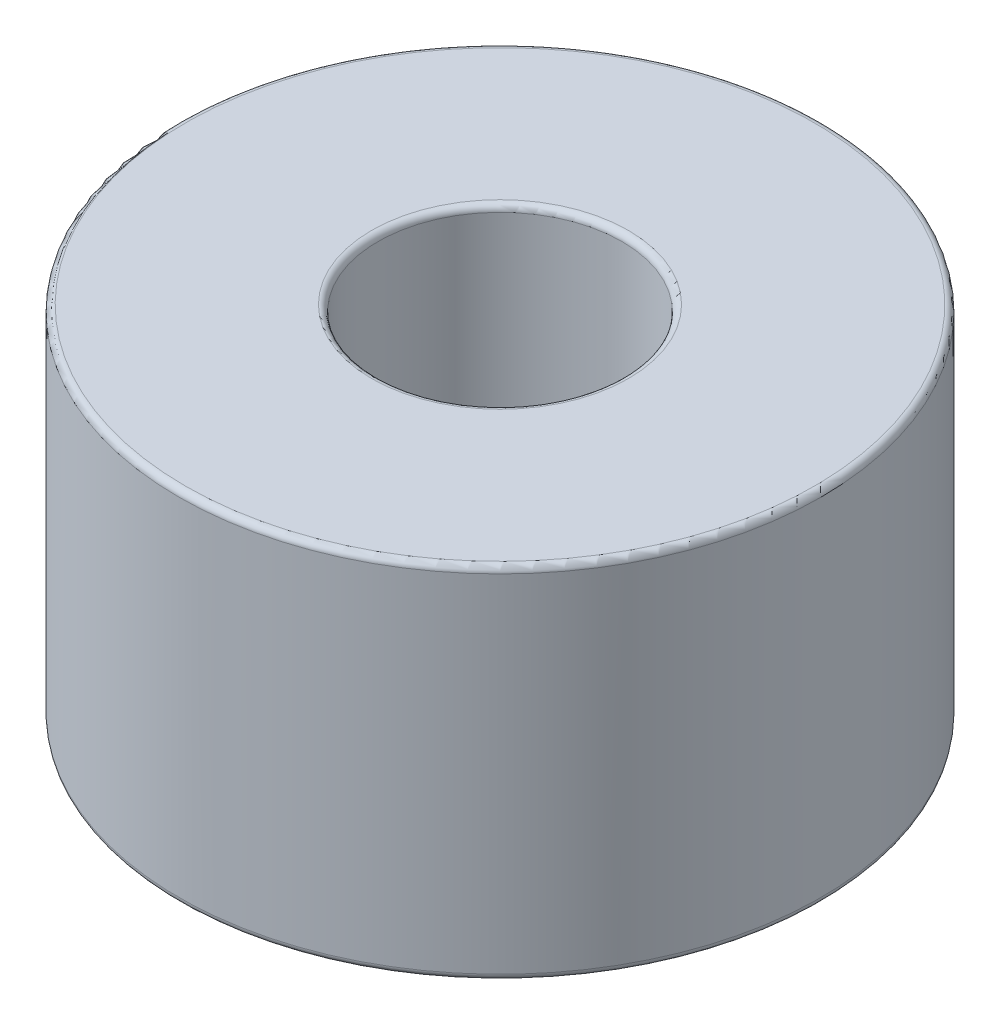
from build123d import *

# Parameters (mm, degrees)
SKETCH1_W = 7.75
SKETCH1_H = 14
FILLET1_R = 0.25


with BuildPart() as part:
    # Sketch1 → Revolve1 (revolve)
    with BuildSketch(Plane.XY):
        with Locations((8.625, 7)):
            Rectangle(SKETCH1_W, SKETCH1_H)
    revolve(axis=Axis((0, 0, 0), (0, 1, 0)))

    # Fillet1
    fillet1_edges = [part.edges().sort_by_distance(p)[0] for p in [
        (-4.75, 14, 0),
        (-12.5, 14, 0),
        (-12.5, 0, 0),
        (-4.75, 0, 0),
    ]]
    fillet(fillet1_edges, radius=FILLET1_R)


solid = part.part
